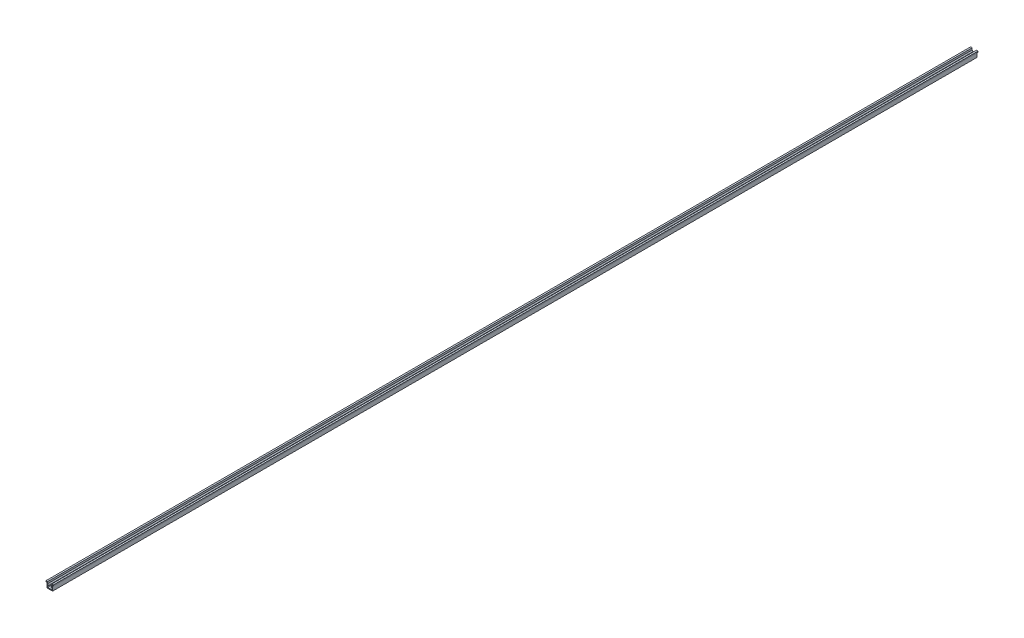
from build123d import *

# Parameters (mm, degrees)
EXTRUDE_1_DEPTH = 1000


with BuildPart() as part:
    # Эскиз1 → Бобышка-Вытянуть1 (new body)
    with BuildSketch(Plane.XY):
        Polygon((3.1, 0), (-3.1, 0), (-3.1, 5.3), (-4, 5.3), (-4, 6.3), (-2.25, 6.3), (-2.25, 4.3), (-1.189339828, 3.239339828), (-1.613603897, 2.81507576), (-2.25, 3.451471863), (-2.25, 0.85), (2.25, 0.85), (2.25, 3.451471863), (1.613603897, 2.81507576), (1.189339828, 3.239339828), (2.25, 4.3), (2.25, 6.3), (4, 6.3), (4, 5.3), (3.1, 5.3), align=None)
    extrude(amount=EXTRUDE_1_DEPTH)


solid = part.part
